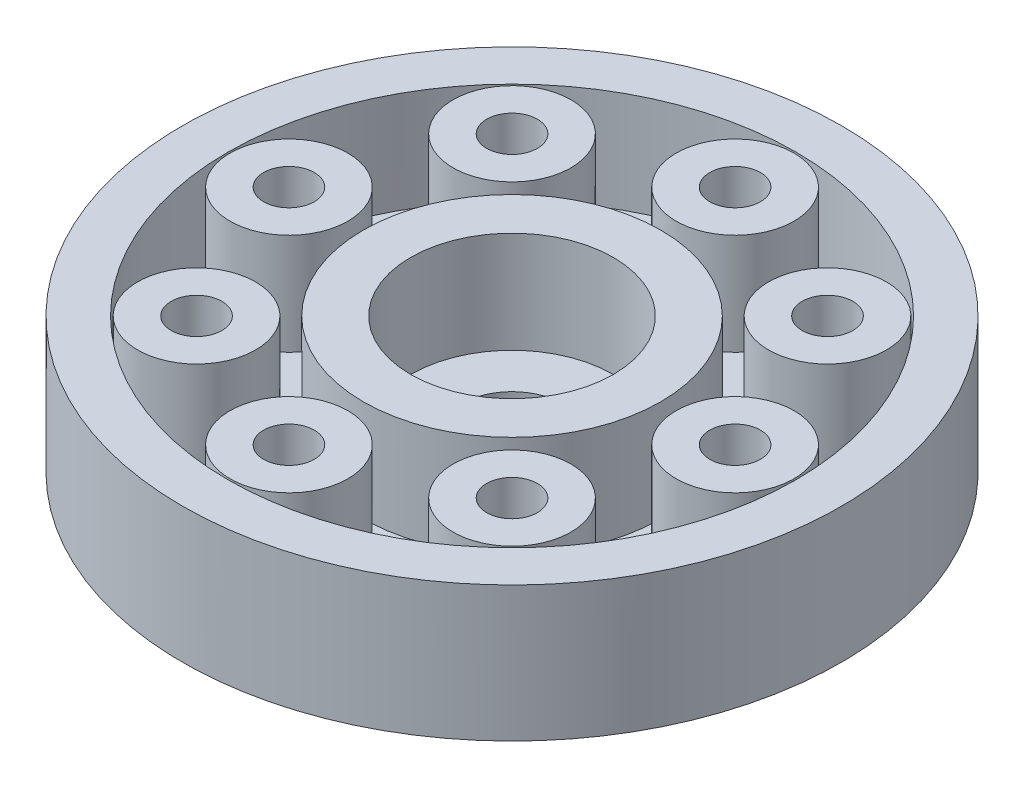
from build123d import *

# Parameters (mm, degrees)
SKETCH_1_R          = 9.75
EXTRUDE_1_DEPTH     = 3
SKETCH_2_R          = 9.75
EXTRUDE_2_DEPTH     = 1
SKETCH_4_R          = 1.5
CUT_EXTRUDE_4_DEPTH = 1
SKETCH_5_R          = 8.4
SKETCH_5_R_2        = 4.4
CUT_EXTRUDE_5_DEPTH = 10
SKETCH_6_R          = 1.744482362
SKETCH_6_R_2        = 0.75
EXTRUDE_3_DEPTH     = 3
SKETCH_7_R          = 0.75
SKETCH_7_R_2        = 1.5
CUT_EXTRUDE_6_DEPTH = 3
SKETCH_8_R          = 4
CUT_EXTRUDE_7_DEPTH = 3
SKETCH_9_R          = 4
SKETCH_9_R_2        = 3
EXTRUDE_4_DEPTH     = 3


with BuildPart() as part:
    # 草图1 → 凸台-拉伸1 (new body)
    with BuildSketch(Plane(origin=(0, 0, 0), x_dir=(1, 0, 0), z_dir=(0, 1, 0))):
        with Locations((0.394660743, -0.591991115)):
            Circle(SKETCH_1_R)
        with BuildLine():
            ThreePointArc((-0.026116093, 2.25205035), (-0.201664975, 2.520045602), (-0.42818362, 2.746602811))
            ThreePointArc((-0.42818362, 2.746602811), (-0.460459434, 2.738482084), (-0.492655135, 2.73004934))
            ThreePointArc((-0.492655135, 2.73004934), (-0.582010169, 2.422389555), (-0.606737129, 2.102972206))
            ThreePointArc((-0.606737129, 2.102972206), (-0.663697346, 2.081116282), (-0.720180966, 2.058056613))
            ThreePointArc((-0.720180966, 2.058056613), (-0.956862366, 2.27397507), (-1.232606998, 2.437081672))
            ThreePointArc((-1.232606998, 2.437081672), (-1.261849265, 2.421189404), (-1.290936341, 2.405014844))
            ThreePointArc((-1.290936341, 2.405014844), (-1.300972245, 2.084799064), (-1.245486498, 1.769267453))
            ThreePointArc((-1.245486498, 1.769267453), (-1.295221857, 1.733932744), (-1.344196234, 1.697550632))
            ThreePointArc((-1.344196234, 1.697550632), (-1.62713859, 1.847825343), (-1.934783159, 1.937232749))
            ThreePointArc((-1.934783159, 1.937232749), (-1.95915448, 1.91456751), (-1.983305283, 1.891667442))
            ThreePointArc((-1.983305283, 1.891667442), (-1.913391464, 1.579016002), (-1.781179383, 1.287196141))
            ThreePointArc((-1.781179383, 1.287196141), (-1.82056483, 1.240602855), (-1.858952723, 1.193184322))
            ThreePointArc((-1.858952723, 1.193184322), (-2.170377725, 1.268372974), (-2.490591793, 1.278463389))
            ThreePointArc((-2.490591793, 1.278463389), (-2.508560828, 1.250449319), (-2.526257873, 1.222262639))
            ThreePointArc((-2.526257873, 1.222262639), (-2.380787274, 0.936820578), (-2.180156231, 0.687048582))
            ThreePointArc((-2.180156231, 0.687048582), (-2.206717032, 0.632124348), (-2.23210639, 0.576648875))
            ThreePointArc((-2.23210639, 0.576648875), (-2.552446061, 0.572027088), (-2.865109398, 0.502166494))
            ThreePointArc((-2.865109398, 0.502166494), (-2.875547088, 0.47056382), (-2.885678405, 0.4388616))
            ThreePointArc((-2.885678405, 0.4388616), (-2.673791479, 0.198564293), (-2.417347859, 0.006534255))
            ThreePointArc((-2.417347859, 0.006534255), (-2.429415102, -0.053269836), (-2.440210618, -0.113316522))
            ThreePointArc((-2.440210618, -0.113316522), (-2.749336837, -0.197458343), (-3.034803657, -0.342880348))
            ThreePointArc((-3.034803657, -0.342880348), (-3.037054162, -0.376085914), (-3.038983164, -0.409311707))
            ThreePointArc((-3.038983164, -0.409311707), (-2.773993545, -0.589365496), (-2.477850645, -0.711587622))
            ThreePointArc((-2.477850645, -0.711587622), (-2.474666101, -0.772513859), (-2.470189451, -0.833358803))
            ThreePointArc((-2.470189451, -0.833358803), (-2.748678682, -0.991733719), (-2.989012055, -1.203579736))
            ThreePointArc((-2.989012055, -1.203579736), (-2.982933968, -1.236301765), (-2.976539448, -1.268963432))
            ThreePointArc((-2.976539448, -1.268963432), (-2.675097409, -1.377460262), (-2.357862976, -1.422194811))
            ThreePointArc((-2.357862976, -1.422194811), (-2.339626741, -1.480414974), (-2.320159211, -1.538235065))
            ThreePointArc((-2.320159211, -1.538235065), (-2.550512951, -1.760891797), (-2.730611847, -2.025850761))
            ThreePointArc((-2.730611847, -2.025850761), (-2.716587076, -2.056033209), (-2.702270826, -2.086078497))
            ThreePointArc((-2.702270826, -2.086078497), (-2.383317078, -2.116201113), (-2.064924118, -2.080637248))
            ThreePointArc((-2.064924118, -2.080637248), (-2.032782042, -2.132493151), (-1.999546849, -2.18365534))
            ThreePointArc((-1.999546849, -2.18365534), (-2.167291125, -2.456603546), (-2.275839268, -2.758027112))
            ThreePointArc((-2.275839268, -2.758027112), (-2.254749042, -2.783773504), (-2.233410603, -2.809314557))
            ThreePointArc((-2.233410603, -2.809314557), (-1.916986184, -2.759170244), (-1.617440498, -2.645542574))
            ThreePointArc((-1.617440498, -2.645542574), (-1.573412186, -2.687775919), (-1.528497619, -2.729065497))
            ThreePointArc((-1.528497619, -2.729065497), (-1.623092441, -3.035154839), (-1.653269352, -3.354103454))
            ThreePointArc((-1.653269352, -3.354103454), (-1.626438847, -3.37379605), (-1.599418993, -3.393228031))
            ThreePointArc((-1.599418993, -3.393228031), (-1.305406012, -3.26596754), (-1.043529157, -3.081415709))
            ThreePointArc((-1.043529157, -3.081415709), (-0.99038107, -3.11137282), (-0.936609275, -3.140195412))
            ThreePointArc((-0.936609275, -3.140195412), (-0.952110903, -3.460193169), (-0.902020456, -3.77662612))
            ThreePointArc((-0.902020456, -3.77662612), (-0.871135531, -3.789027562), (-0.840132018, -3.801129486))
            ThreePointArc((-0.840132018, -3.801129486), (-0.587004393, -3.604749063), (-0.379251055, -3.360869142))
            ThreePointArc((-0.379251055, -3.360869142), (-0.320322682, -3.376667703), (-0.261072341, -3.391212279))
            ThreePointArc((-0.261072341, -3.391212279), (-0.19650675, -3.705011816), (-0.069296312, -3.999046457))
            ThreePointArc((-0.069296312, -3.999046457), (-0.03629758, -4.003377516), (-0.003258474, -4.007388976))
            ThreePointArc((-0.003258474, -4.007388976), (0.193078856, -3.754227924), (0.333654771, -3.466343785))
            ThreePointArc((0.333654771, -3.466343785), (0.394660743, -3.466991115), (0.455666715, -3.466343785))
            ThreePointArc((0.455666715, -3.466343785), (0.596242631, -3.754227924), (0.792579961, -4.007388976))
            ThreePointArc((0.792579961, -4.007388976), (0.825619067, -4.003377516), (0.858617799, -3.999046457))
            ThreePointArc((0.858617799, -3.999046457), (0.985828237, -3.705011816), (1.050393827, -3.391212279))
            ThreePointArc((1.050393827, -3.391212279), (1.109644169, -3.376667703), (1.168572542, -3.360869142))
            ThreePointArc((1.168572542, -3.360869142), (1.37632588, -3.604749063), (1.629453505, -3.801129486))
            ThreePointArc((1.629453505, -3.801129486), (1.660457018, -3.789027562), (1.691341943, -3.77662612))
            ThreePointArc((1.691341943, -3.77662612), (1.74143239, -3.460193169), (1.725930762, -3.140195412))
            ThreePointArc((1.725930762, -3.140195412), (1.779702556, -3.11137282), (1.832850644, -3.081415709))
            ThreePointArc((1.832850644, -3.081415709), (2.094727499, -3.26596754), (2.388740479, -3.393228031))
            ThreePointArc((2.388740479, -3.393228031), (2.415760333, -3.37379605), (2.442590839, -3.354103454))
            ThreePointArc((2.442590839, -3.354103454), (2.412413927, -3.035154839), (2.317819105, -2.729065497))
            ThreePointArc((2.317819105, -2.729065497), (2.362733673, -2.687775919), (2.406761985, -2.645542574))
            ThreePointArc((2.406761985, -2.645542574), (2.706307671, -2.759170244), (3.02273209, -2.809314557))
            ThreePointArc((3.02273209, -2.809314557), (3.044070529, -2.783773504), (3.065160755, -2.758027112))
            ThreePointArc((3.065160755, -2.758027112), (2.956612612, -2.456603546), (2.788868336, -2.18365534))
            ThreePointArc((2.788868336, -2.18365534), (2.822103529, -2.132493151), (2.854245605, -2.080637248))
            ThreePointArc((2.854245605, -2.080637248), (3.172638565, -2.116201113), (3.491592313, -2.086078497))
            ThreePointArc((3.491592313, -2.086078497), (3.505908563, -2.056033209), (3.519933334, -2.025850761))
            ThreePointArc((3.519933334, -2.025850761), (3.339834438, -1.760891797), (3.109480698, -1.538235065))
            ThreePointArc((3.109480698, -1.538235065), (3.128948228, -1.480414974), (3.147184462, -1.422194811))
            ThreePointArc((3.147184462, -1.422194811), (3.464418895, -1.377460262), (3.765860935, -1.268963432))
            ThreePointArc((3.765860935, -1.268963432), (3.772255455, -1.236301765), (3.778333542, -1.203579736))
            ThreePointArc((3.778333542, -1.203579736), (3.538000169, -0.991733719), (3.259510938, -0.833358803))
            ThreePointArc((3.259510938, -0.833358803), (3.263987588, -0.772513859), (3.267172132, -0.711587622))
            ThreePointArc((3.267172132, -0.711587622), (3.563315032, -0.589365496), (3.828304651, -0.409311707))
            ThreePointArc((3.828304651, -0.409311707), (3.826375649, -0.376085914), (3.824125144, -0.342880348))
            ThreePointArc((3.824125144, -0.342880348), (3.538658323, -0.197458343), (3.229532104, -0.113316522))
            ThreePointArc((3.229532104, -0.113316522), (3.218736589, -0.053269836), (3.206669346, 0.006534255))
            ThreePointArc((3.206669346, 0.006534255), (3.463112965, 0.198564293), (3.674999892, 0.4388616))
            ThreePointArc((3.674999892, 0.4388616), (3.664868575, 0.47056382), (3.654430885, 0.502166494))
            ThreePointArc((3.654430885, 0.502166494), (3.341767547, 0.572027088), (3.021427877, 0.576648875))
            ThreePointArc((3.021427877, 0.576648875), (2.996038519, 0.632124348), (2.969477718, 0.687048582))
            ThreePointArc((2.969477718, 0.687048582), (3.170108761, 0.936820578), (3.31557936, 1.222262639))
            ThreePointArc((3.31557936, 1.222262639), (3.297882315, 1.250449319), (3.279913279, 1.278463389))
            ThreePointArc((3.279913279, 1.278463389), (2.959699212, 1.268372974), (2.64827421, 1.193184322))
            ThreePointArc((2.64827421, 1.193184322), (2.609886316, 1.240602855), (2.57050087, 1.287196141))
            ThreePointArc((2.57050087, 1.287196141), (2.702712951, 1.579016002), (2.772626769, 1.891667442))
            ThreePointArc((2.772626769, 1.891667442), (2.748475967, 1.91456751), (2.724104646, 1.937232749))
            ThreePointArc((2.724104646, 1.937232749), (2.416460076, 1.847825343), (2.133517721, 1.697550632))
            ThreePointArc((2.133517721, 1.697550632), (2.084543344, 1.733932744), (2.034807985, 1.769267453))
            ThreePointArc((2.034807985, 1.769267453), (2.090293731, 2.084799064), (2.080257828, 2.405014844))
            ThreePointArc((2.080257828, 2.405014844), (2.051170752, 2.421189404), (2.021928485, 2.437081672))
            ThreePointArc((2.021928485, 2.437081672), (1.746183853, 2.27397507), (1.509502453, 2.058056613))
            ThreePointArc((1.509502453, 2.058056613), (1.453018832, 2.081116282), (1.396058616, 2.102972206))
            ThreePointArc((1.396058616, 2.102972206), (1.371331655, 2.422389555), (1.281976622, 2.73004934))
            ThreePointArc((1.281976622, 2.73004934), (1.24978092, 2.738482084), (1.217505107, 2.746602811))
            ThreePointArc((1.217505107, 2.746602811), (0.990986462, 2.520045602), (0.81543758, 2.25205035))
            ThreePointArc((0.81543758, 2.25205035), (0.75499379, 2.260338651), (0.694387736, 2.267342501))
            ThreePointArc((0.694387736, 2.267342501), (0.591001754, 2.570575422), (0.427942096, 2.846347815))
            ThreePointArc((0.427942096, 2.846347815), (0.394660743, 2.846508885), (0.361379391, 2.846347815))
            ThreePointArc((0.361379391, 2.846347815), (0.198319733, 2.570575422), (0.094933751, 2.267342501))
            ThreePointArc((0.094933751, 2.267342501), (0.034327697, 2.260338651), (-0.026116093, 2.25205035))
        make_face(mode=Mode.SUBTRACT)
    extrude(amount=EXTRUDE_1_DEPTH)

    # 草图2 → 凸台-拉伸2 (add)
    with BuildSketch(Plane(origin=(0, 0, 0), x_dir=(-1, 0, 0), z_dir=(0, -1, 0))):
        with Locations((-0.394660743, -0.591991115)):
            Circle(SKETCH_2_R)
    extrude(amount=EXTRUDE_2_DEPTH)

    # 草图4 → 切除-拉伸4 (cut)
    with BuildSketch(Plane(origin=(0, 0, 0), x_dir=(1, 0, 0), z_dir=(0, 1, 0))):
        with Locations((0.394660743, -0.591991115)):
            Circle(SKETCH_4_R)
    extrude(amount=-CUT_EXTRUDE_4_DEPTH, mode=Mode.SUBTRACT)

    # 草图5 → 切除-拉伸5 (cut)
    with BuildSketch(Plane(origin=(0, 0, 0), x_dir=(-1, 0, 0), z_dir=(0, -1, 0))):
        with Locations((-0.394660743, -0.591991115)):
            Circle(SKETCH_5_R)
        with Locations((-0.394660743, -0.591991115)):
            Circle(SKETCH_5_R_2, mode=Mode.SUBTRACT)
    extrude(amount=-CUT_EXTRUDE_5_DEPTH, mode=Mode.SUBTRACT)

    # 草图6 → 凸台-拉伸3 (add)
    with BuildSketch(Plane(origin=(0, 0, 0), x_dir=(-1, 0, 0), z_dir=(0, -1, 0))):
        with Locations((-0.394660743, 6.008008885)):
            Circle(SKETCH_6_R)
        with Locations((-0.394660743, 6.008008885)):
            Circle(SKETCH_6_R_2, mode=Mode.SUBTRACT)
        with Locations((4.272244012, 4.074913641)):
            Circle(SKETCH_6_R)
        with Locations((4.272244012, 4.074913641)):
            Circle(SKETCH_6_R_2, mode=Mode.SUBTRACT)
        with Locations((6.205339257, -0.591991115)):
            Circle(SKETCH_6_R)
        with Locations((6.205339257, -0.591991115)):
            Circle(SKETCH_6_R_2, mode=Mode.SUBTRACT)
        with Locations((4.272244012, -5.258895871)):
            Circle(SKETCH_6_R)
        with Locations((4.272244012, -5.258895871)):
            Circle(SKETCH_6_R_2, mode=Mode.SUBTRACT)
        with Locations((-0.394660743, -7.191991115)):
            Circle(SKETCH_6_R)
        with Locations((-0.394660743, -7.191991115)):
            Circle(SKETCH_6_R_2, mode=Mode.SUBTRACT)
        with Locations((-5.061565499, -5.258895871)):
            Circle(SKETCH_6_R)
        with Locations((-5.061565499, -5.258895871)):
            Circle(SKETCH_6_R_2, mode=Mode.SUBTRACT)
        with Locations((-6.994660743, -0.591991115)):
            Circle(SKETCH_6_R)
        with Locations((-6.994660743, -0.591991115)):
            Circle(SKETCH_6_R_2, mode=Mode.SUBTRACT)
        with Locations((-5.061565499, 4.074913641)):
            Circle(SKETCH_6_R)
        with Locations((-5.061565499, 4.074913641)):
            Circle(SKETCH_6_R_2, mode=Mode.SUBTRACT)
    extrude(amount=-EXTRUDE_3_DEPTH)

    # 草图7 → 切除-拉伸6 (cut)
    with BuildSketch(Plane(origin=(0, -1, 0), x_dir=(-1, 0, 0), z_dir=(0, -1, 0))):
        with Locations((-0.394660743, 6.008008885)):
            Circle(SKETCH_7_R)
        with Locations((-0.394660743, -0.591991115)):
            Circle(SKETCH_7_R_2)
        with Locations((4.272244012, 4.074913641)):
            Circle(SKETCH_7_R)
        with Locations((6.205339257, -0.591991115)):
            Circle(SKETCH_7_R)
        with Locations((4.272244012, -5.258895871)):
            Circle(SKETCH_7_R)
        with Locations((-0.394660743, -7.191991115)):
            Circle(SKETCH_7_R)
        with Locations((-5.061565499, -5.258895871)):
            Circle(SKETCH_7_R)
        with Locations((-6.994660743, -0.591991115)):
            Circle(SKETCH_7_R)
        with Locations((-5.061565499, 4.074913641)):
            Circle(SKETCH_7_R)
    extrude(amount=-CUT_EXTRUDE_6_DEPTH, mode=Mode.SUBTRACT)

    # 草图8 → 切除-拉伸7 (cut)
    with BuildSketch(Plane(origin=(0, 3, 0), x_dir=(1, 0, 0), z_dir=(0, 1, 0))):
        with Locations((0.394660743, -0.591991115)):
            Circle(SKETCH_8_R)
    extrude(amount=-CUT_EXTRUDE_7_DEPTH, mode=Mode.SUBTRACT)

    # 草图9 → 凸台-拉伸4 (add)
    with BuildSketch(Plane(origin=(0, 0, 0), x_dir=(1, 0, 0), z_dir=(0, 1, 0))):
        with Locations((0.394660743, -0.591991115)):
            Circle(SKETCH_9_R)
        with Locations((0.394660743, -0.591991115)):
            Circle(SKETCH_9_R_2, mode=Mode.SUBTRACT)
    extrude(amount=EXTRUDE_4_DEPTH)


solid = part.part
